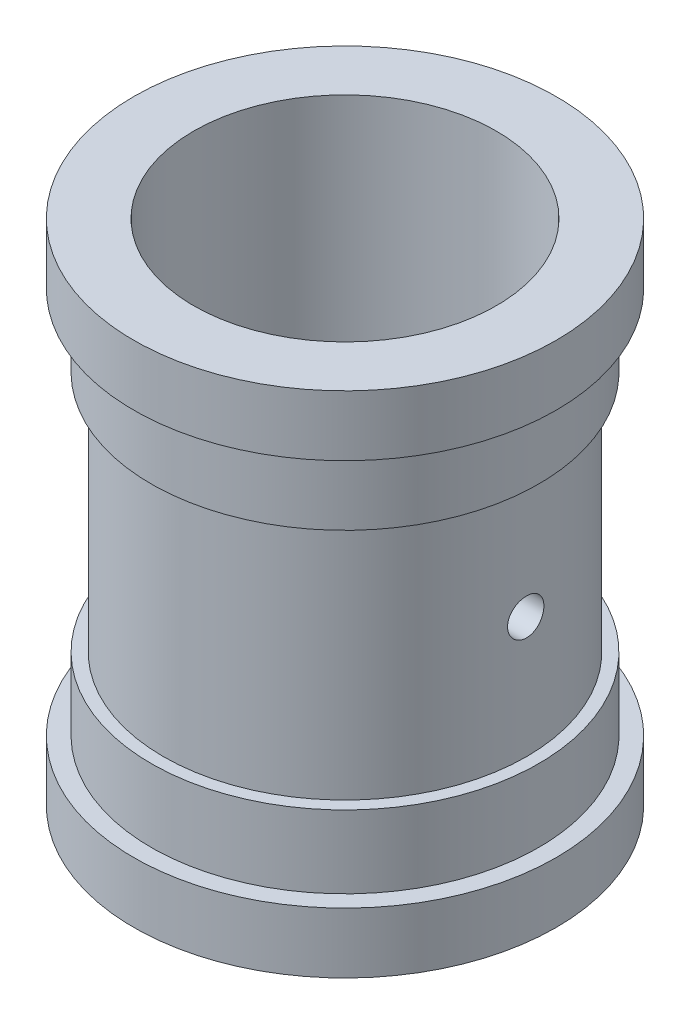
from build123d import *

# Parameters (mm, degrees)
SKETCH4_R          = 25
CUT_EXTRUDE1_DEPTH = 106
SKETCH5_R          = 3
CUT_EXTRUDE2_DEPTH = 35


with BuildPart() as part:
    # Sketch2 → Revolve2 (revolve)
    with BuildSketch(Plane.XY):
        Polygon((0, 42), (0, -42), (34.886559364, -42), (34.886559364, -32), (32, -32), (32, -20), (30, -20), (30, 20), (32, 20), (32, 32), (34.886559364, 32), (34.886559364, 42), align=None)
    revolve(axis=Axis((0, 42, 0), (0, -1, 0)))

    # Sketch4 → Cut-Extrude1 (cut)
    with BuildSketch(Plane(origin=(0, 42, 0), x_dir=(1, 0, 0), z_dir=(0, 1, 0))):
        Circle(SKETCH4_R)
    extrude(amount=-CUT_EXTRUDE1_DEPTH, mode=Mode.SUBTRACT)

    # Sketch5 → Cut-Extrude2 (cut, symmetric)
    with BuildSketch(Plane(origin=(0, 0, 0), x_dir=(0, 0, -1), z_dir=(1, 0, 0))):
        Circle(SKETCH5_R)
    extrude(amount=CUT_EXTRUDE2_DEPTH, both=True, mode=Mode.SUBTRACT)


solid = part.part
